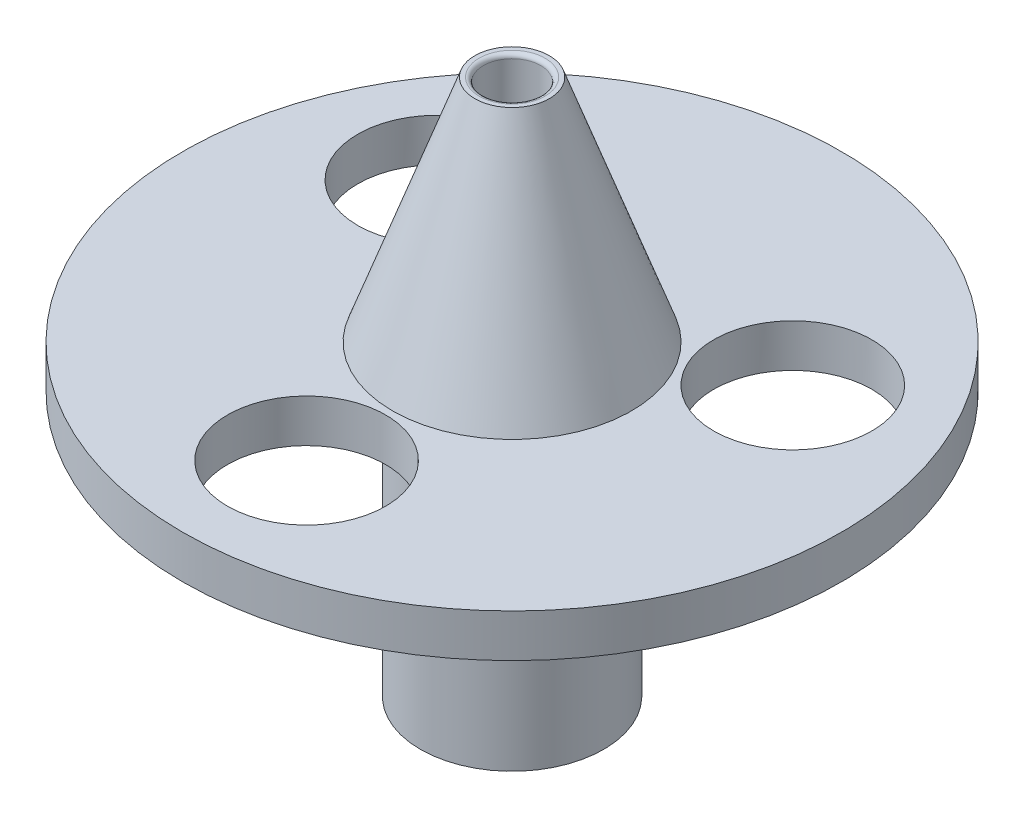
from build123d import *

# Parameters (mm, degrees)
FILLET1_R               = 0.3
SKETCH3_R               = 3.6
CUT_EXTRUDE1_DEPTH      = 1
CUT_EXTRUDE1_DEPTH_BACK = 22
FILLET2_R               = 0.5
FILLET3_R               = 0.5
SKETCH5_W               = 6.5
SKETCH5_H               = 2
SKETCH6_W               = 8.5
SKETCH6_H               = 2
SKETCH8_W               = 8.5
SKETCH8_H               = 3
SKETCH7_W               = 6.5
SKETCH7_H               = 3
SKETCH11_R              = 5.52
CUT_EXTRUDE3_DEPTH      = 10
CUT_EXTRUDE4_DEPTH      = 10
BOSS_EXTRUDE1_DEPTH     = 3
SKETCH15_R              = 23
SKETCH15_R_2            = 8.340902118
SKETCH15_R_3            = 5.6
BOSS_EXTRUDE4_DEPTH     = 3
SKETCH16_R              = 5.52
CUT_EXTRUDE6_DEPTH      = 3


with BuildPart() as part:
    # Sketch2 → Revolve1 (revolve)
    with BuildSketch(Plane.XY):
        Polygon((2, 0), (2.6, 0), (8.340902118, -16), (20.340902118, -16), (20.340902118, -19), (6.4, -19), (6.4, -37.427752697), (3.4, -37.427752697), (3.4, -16), (2, -16), align=None)
    revolve(axis=Axis((0, 0, 0), (0, -1, 0)))

    # Fillet1
    fillet1_edges = [part.edges().sort_by_distance(p)[0] for p in [
        (-2, 0, 0),
    ]]
    fillet(fillet1_edges, radius=FILLET1_R)

    # Sketch3 → Cut-Extrude1 (cut, two sides)
    with BuildSketch(Plane.XZ.offset(37.427752697)) as cut_extrude1_sk:
        Circle(SKETCH3_R)
    extrude(amount=CUT_EXTRUDE1_DEPTH, mode=Mode.SUBTRACT)
    extrude(cut_extrude1_sk.sketch, amount=-CUT_EXTRUDE1_DEPTH_BACK, mode=Mode.SUBTRACT)

    # Fillet2
    fillet2_edges = [part.edges().sort_by_distance(p)[0] for p in [
        (-2, -15.427752697, 0),
    ]]
    fillet(fillet2_edges, radius=FILLET2_R)

    # Fillet3
    fillet3_edges = [part.edges().sort_by_distance(p)[0] for p in [
        (-3.6, -37.427752697, 0),
    ]]
    fillet(fillet3_edges, radius=FILLET3_R)

    # Sketch5 → Cut-Loft2 section 0
    with BuildSketch(Plane(origin=(0, -16, 0), x_dir=(1, 0, 0), z_dir=(0, 1, 0))):
        with Locations((0, -15)):
            Rectangle(SKETCH5_W, SKETCH5_H)
    # Sketch6 → Cut-Loft2 section 1
    with BuildSketch(Plane.XZ.offset(19)):
        with Locations((0, 15)):
            Rectangle(SKETCH6_W, SKETCH6_H)
    loft(mode=Mode.SUBTRACT)

    # Sketch8 → Cut-Loft3 section 0
    with BuildSketch(Plane.XZ.offset(19)):
        with Locations((0, 15)):
            Rectangle(SKETCH8_W, SKETCH8_H)
    # Sketch7 → Cut-Loft3 section 1
    with BuildSketch(Plane(origin=(0, -16, 0), x_dir=(1, 0, 0), z_dir=(0, 1, 0))):
        with Locations((0, -15)):
            Rectangle(SKETCH7_W, SKETCH7_H)
    loft(mode=Mode.SUBTRACT)

    # Sketch11 → Cut-Extrude3 (cut)
    with BuildSketch(Plane(origin=(0, -16, 0), x_dir=(1, 0, 0), z_dir=(0, 1, 0))):
        with Locations((0, 14.340902118)):
            Circle(SKETCH11_R)
        with Locations((12.419585547, 7.170451059)):
            Circle(SKETCH11_R)
        with BuildLine():
            ThreePointArc((-17.200045776, 9.930451059), (-15.179585547, 2.38999083), (-7.639125318, 4.410451059))
            Line((-7.639125318, 4.410451059), (-12.419585547, 7.170451059))
            Line((-12.419585547, 7.170451059), (-17.200045776, 9.930451059))
        make_face()
        with BuildLine():
            Line((-12.419585547, 7.170451059), (-7.639125318, 4.410451059))
            ThreePointArc((-7.639125318, 4.410451059), (-7.087674986, 5.74176993), (-6.899585547, 7.170451059))
            ThreePointArc((-6.899585547, 7.170451059), (-10.990904418, 12.50236162), (-17.200045776, 9.930451059))
            Line((-17.200045776, 9.930451059), (-12.419585547, 7.170451059))
        make_face()
    extrude(amount=-CUT_EXTRUDE3_DEPTH, mode=Mode.SUBTRACT)

    # Sketch13 → Cut-Extrude4 (cut)
    with BuildSketch(Plane(origin=(0, -16, 0), x_dir=(1, 0, 0), z_dir=(0, 1, 0))):
        with BuildLine():
            Line((-8.340902118, 0), (-20.340902118, 0))
            ThreePointArc((-20.340902118, 0), (-17.61573797, -10.170451059), (-10.170451059, -17.61573797))
            Line((-10.170451059, -17.61573797), (-4.170451059, -7.223433125))
            ThreePointArc((-4.170451059, -7.223433125), (-7.223433125, -4.170451059), (-8.340902118, 0))
        make_face()
        with BuildLine():
            Line((8.340902118, 0), (20.340902118, 0))
            ThreePointArc((20.340902118, 0), (17.546873261, -10.288806428), (9.932362997, -17.751069384))
            Line((9.932362997, -17.751069384), (4.072821701, -7.278926537))
            ThreePointArc((4.072821701, -7.278926537), (7.195194761, -4.218983349), (8.340902118, 0))
        make_face()
    extrude(amount=-CUT_EXTRUDE4_DEPTH, mode=Mode.SUBTRACT)

    # Sketch14 → Boss-Extrude1 (add)
    with BuildSketch(Plane(origin=(0, -16, 0), x_dir=(1, 0, 0), z_dir=(0, 1, 0))):
        with BuildLine():
            ThreePointArc((0, 20.340902118), (14.383189823, 14.383189823), (20.340902118, 0))
            Line((20.340902118, 0), (23, 0))
            ThreePointArc((23, 0), (16.263455967, 16.263455967), (0, 23))
            Line((0, 23), (0, 20.340902118))
        make_face()
        with BuildLine():
            Line((-23, 0), (-20.340902118, 0))
            ThreePointArc((-20.340902118, 0), (-14.383189823, 14.383189823), (0, 20.340902118))
            Line((0, 20.340902118), (0, 23))
            ThreePointArc((0, 23), (-16.263455967, 16.263455967), (-23, 0))
        make_face()
    extrude(amount=-BOSS_EXTRUDE1_DEPTH)

    # Sketch15 → Boss-Extrude4 (add)
    with BuildSketch(Plane(origin=(0, -16, 0), x_dir=(1, 0, 0), z_dir=(0, 1, 0))):
        Circle(SKETCH15_R)
        Circle(SKETCH15_R_2, mode=Mode.SUBTRACT)
        with Locations((-12.419585547, 7.170451059)):
            Circle(SKETCH15_R_3, mode=Mode.SUBTRACT)
        with Locations((12.419585547, 7.170451059)):
            Circle(SKETCH15_R_3, mode=Mode.SUBTRACT)
        with Locations((0, -14.340902118)):
            Circle(SKETCH15_R_3, mode=Mode.SUBTRACT)
    extrude(amount=-BOSS_EXTRUDE4_DEPTH)

    # Sketch16 → Cut-Extrude6 (cut)
    with BuildSketch(Plane(origin=(0, -16, 0), x_dir=(1, 0, 0), z_dir=(0, 1, 0))):
        with Locations((0, -14.34090212)):
            Circle(SKETCH16_R)
    extrude(amount=-CUT_EXTRUDE6_DEPTH, mode=Mode.SUBTRACT)


solid = part.part
